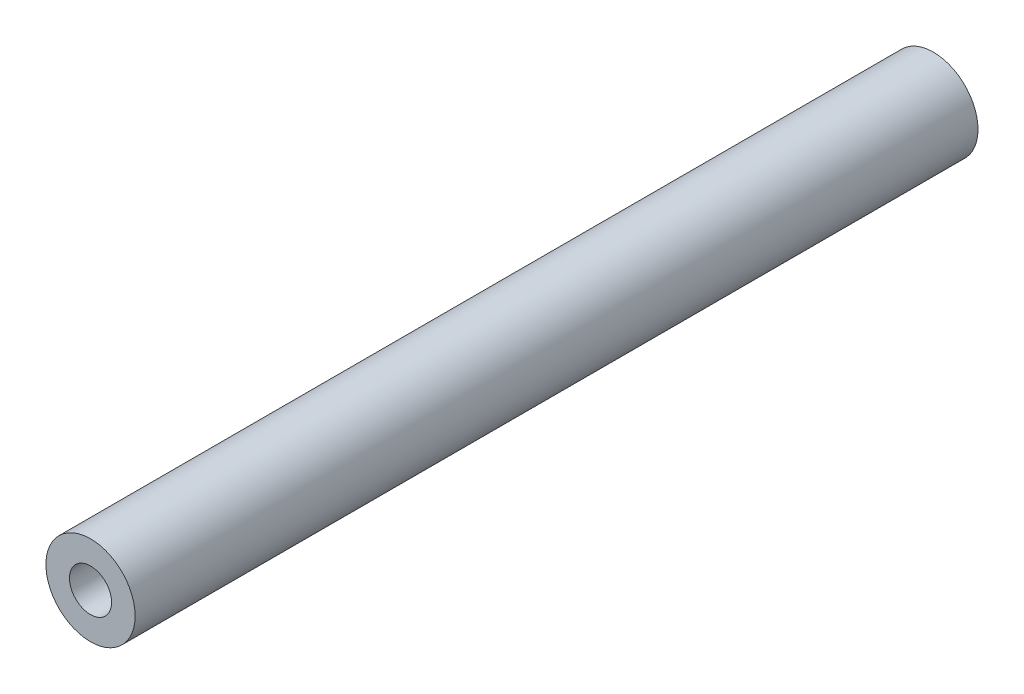
from build123d import *

# Parameters (mm, degrees)
SKETCH1_R                = 1.5875
BOSS_EXTRUDE1_DEPTH      = 6.35
BOSS_EXTRUDE1_DEPTH_BACK = 31.304
SKETCH2_R                = 1.5875
CUT_EXTRUDE1_DEPTH       = 7.654
SKETCH3_R                = 0.750000024
CUT_EXTRUDE2_DEPTH       = 12.7
CUT_EXTRUDE2_TAPER       = 1


with BuildPart() as part:
    # Sketch1 → Boss-Extrude1 (new body, two sides)
    with BuildSketch(Plane.XY) as boss_extrude1_sk:
        Circle(SKETCH1_R)
    extrude(amount=BOSS_EXTRUDE1_DEPTH)
    extrude(boss_extrude1_sk.sketch, amount=-BOSS_EXTRUDE1_DEPTH_BACK)

    # Sketch2 → Cut-Extrude1 (cut)
    with BuildSketch(Plane(origin=(0, 0, -31.304), x_dir=(-1, 0, 0), z_dir=(0, 0, -1))):
        Circle(SKETCH2_R)
    extrude(amount=-CUT_EXTRUDE1_DEPTH, mode=Mode.SUBTRACT)

    # Sketch3 → Cut-Extrude2 (cut)
    with BuildSketch(Plane.XY.offset(6.35)):
        Circle(SKETCH3_R)
    extrude(amount=-CUT_EXTRUDE2_DEPTH, taper=CUT_EXTRUDE2_TAPER, mode=Mode.SUBTRACT)


solid = part.part
